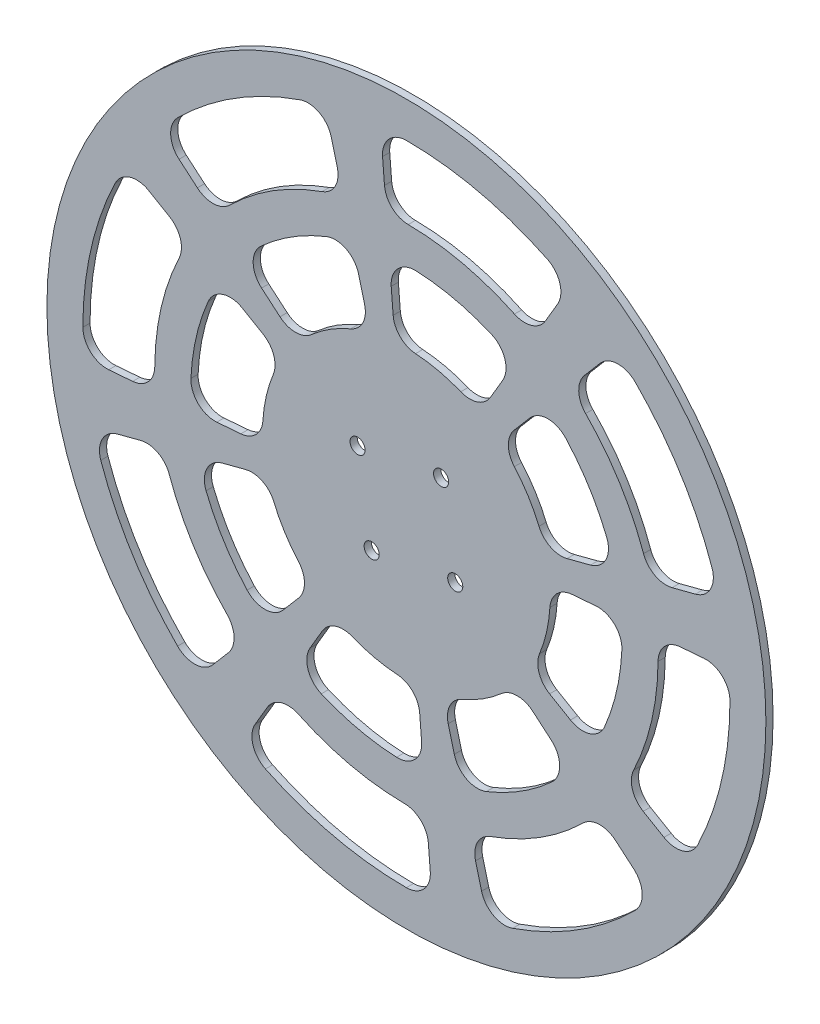
from build123d import *

# Parameters (mm, degrees)
SKETCH1_R           = 150
SKETCH1_R_2         = 3.15
BOSS_EXTRUDE2_DEPTH = 3
CUTOUTS_DEPTH       = 4


with BuildPart() as part:
    # Sketch1 → Boss-Extrude2 (new body)
    with BuildSketch(Plane.XY):
        Circle(SKETCH1_R)
        with Locations((20.373277645, -14.488946062)):
            Circle(SKETCH1_R_2, mode=Mode.SUBTRACT)
        with Locations((-14.488946062, -20.373277645)):
            Circle(SKETCH1_R_2, mode=Mode.SUBTRACT)
        with Locations((-20.373277645, 14.488946062)):
            Circle(SKETCH1_R_2, mode=Mode.SUBTRACT)
        with Locations((14.488946062, 20.373277645)):
            Circle(SKETCH1_R_2, mode=Mode.SUBTRACT)
    extrude(amount=BOSS_EXTRUDE2_DEPTH)

    # Weight Reduction Cutouts → Cutouts (cut, through all)
    with BuildSketch(Plane.XY):
        with BuildLine():
            Line((-94.859765477, 80.787529321), (-87.219963023, 74.281074644))
            ThreePointArc((-87.219963023, 74.281074644), (-80.372135282, 71.900885769), (-73.715641938, 74.773017417))
            ThreePointArc((-73.715641938, 74.773017417), (-55.766653389, 88.966737435), (-35.169050383, 98.935018548))
            ThreePointArc((-35.169050383, 98.935018548), (-29.682884625, 103.674219865), (-28.840536931, 110.874809716))
            Line((-28.840536931, 110.874809716), (-31.366747642, 120.586596031))
            ThreePointArc((-31.366747642, 120.586596031), (-36.330701425, 126.888386505), (-44.328270021, 127.514722589))
            ThreePointArc((-44.328270021, 127.514722589), (-71.699982928, 114.385805274), (-95.446060257, 95.472768795))
            ThreePointArc((-95.446060257, 95.472768795), (-98.36802157, 88.001788778), (-94.859765477, 80.787529321))
        make_face()
        with BuildLine():
            Line((-60.427762956, 51.46343813), (-52.745675776, 44.920971572))
            ThreePointArc((-52.745675776, 44.920971572), (-46.179173953, 42.534496218), (-39.653050302, 45.029274942))
            ThreePointArc((-39.653050302, 45.029274942), (-31.866659079, 50.838135677), (-23.244912146, 55.314320563))
            ThreePointArc((-23.244912146, 55.314320563), (-18.155193347, 60.100652493), (-17.441117348, 67.050782439))
            Line((-17.441117348, 67.050782439), (-19.981310113, 76.816321483))
            ThreePointArc((-19.981310113, 76.816321483), (-25.145953148, 83.222482327), (-33.366664052, 83.586277163))
            ThreePointArc((-33.366664052, 83.586277163), (-47.799988619, 76.257203516), (-60.686976599, 66.461198239))
            ThreePointArc((-60.686976599, 66.461198239), (-63.942485938, 58.903811562), (-60.427762956, 51.46343813))
        make_face()
        with BuildLine():
            Line((63.087959813, 107.447239735), (58.006990576, 98.79366905))
            ThreePointArc((58.006990576, 98.79366905), (52.319774897, 94.297712904), (45.089348498, 94.825896526))
            ThreePointArc((45.089348498, 94.825896526), (23.476004565, 102.341962116), (0.747677371, 104.997337959))
            ThreePointArc((0.747677371, 104.997337959), (-5.990077976, 107.673285777), (-9.149175714, 114.198478903))
            Line((-9.149175714, 114.198478903), (-9.950573612, 124.201393248))
            ThreePointArc((-9.950573612, 124.201393248), (-7.330033503, 131.783356706), (0.018885789, 134.999998679))
            ThreePointArc((0.018885789, 134.999998679), (30.183434441, 131.58252272), (58.821704713, 121.511345374))
            ThreePointArc((58.821704713, 121.511345374), (64.033953208, 115.413323894), (63.087959813, 107.447239735))
        make_face()
        with BuildLine():
            Line((40.188421949, 68.446261704), (35.079330598, 59.744795294))
            ThreePointArc((35.079330598, 59.744795294), (29.659918602, 55.335239261), (22.67649616, 55.549766173))
            ThreePointArc((22.67649616, 55.549766173), (13.414859752, 58.481121209), (3.8015649, 59.879446426))
            ThreePointArc((3.8015649, 59.879446426), (-2.577176342, 62.730037762), (-5.532901403, 69.060748635))
            Line((-5.532901403, 69.060748635), (-6.338734874, 79.119027043))
            ThreePointArc((-6.338734874, 79.119027043), (-3.56288082, 86.865450006), (4.082991278, 89.907336643))
            ThreePointArc((4.082991278, 89.907336643), (20.122289627, 87.721681813), (35.51062898, 82.698217813))
            ThreePointArc((35.51062898, 82.698217813), (41.06630761, 76.628055591), (40.188421949, 68.446261704))
        make_face()
        with BuildLine():
            Line((120.586596031, 31.366747642), (110.874809716, 28.840536931))
            ThreePointArc((110.874809716, 28.840536931), (103.674219865, 29.682884625), (98.935018548, 35.169050383))
            ThreePointArc((98.935018548, 35.169050383), (88.966737435, 55.766653389), (74.773017417, 73.715641938))
            ThreePointArc((74.773017417, 73.715641938), (71.900885769, 80.372135282), (74.281074644, 87.219963023))
            Line((74.281074644, 87.219963023), (80.787529321, 94.859765477))
            ThreePointArc((80.787529321, 94.859765477), (88.001788778, 98.36802157), (95.472768795, 95.446060257))
            ThreePointArc((95.472768795, 95.446060257), (114.385805274, 71.699982928), (127.514722589, 44.328270021))
            ThreePointArc((127.514722589, 44.328270021), (126.888386505, 36.330701425), (120.586596031, 31.366747642))
        make_face()
        with BuildLine():
            Line((76.816321483, 19.981310113), (67.050782439, 17.441117348))
            ThreePointArc((67.050782439, 17.441117348), (60.100652493, 18.155193347), (55.314320563, 23.244912146))
            ThreePointArc((55.314320563, 23.244912146), (50.838135677, 31.866659079), (45.029274942, 39.653050302))
            ThreePointArc((45.029274942, 39.653050302), (42.534496218, 46.179173953), (44.920971572, 52.745675776))
            Line((44.920971572, 52.745675776), (51.46343813, 60.427762956))
            ThreePointArc((51.46343813, 60.427762956), (58.903811562, 63.942485938), (66.461198239, 60.686976599))
            ThreePointArc((66.461198239, 60.686976599), (76.257203516, 47.799988619), (83.586277163, 33.366664052))
            ThreePointArc((83.586277163, 33.366664052), (83.222482327, 25.145953148), (76.816321483, 19.981310113))
        make_face()
        with BuildLine():
            Line((107.447239735, -63.087959813), (98.79366905, -58.006990576))
            ThreePointArc((98.79366905, -58.006990576), (94.297712904, -52.319774897), (94.825896526, -45.089348498))
            ThreePointArc((94.825896526, -45.089348498), (102.341962116, -23.476004565), (104.997337959, -0.747677371))
            ThreePointArc((104.997337959, -0.747677371), (107.673285777, 5.990077976), (114.198478903, 9.149175714))
            Line((114.198478903, 9.149175714), (124.201393248, 9.950573612))
            ThreePointArc((124.201393248, 9.950573612), (131.783356706, 7.330033503), (134.999998679, -0.018885789))
            ThreePointArc((134.999998679, -0.018885789), (131.58252272, -30.183434441), (121.511345374, -58.821704713))
            ThreePointArc((121.511345374, -58.821704713), (115.413323894, -64.033953208), (107.447239735, -63.087959813))
        make_face()
        with BuildLine():
            Line((68.446261704, -40.188421949), (59.744795294, -35.079330598))
            ThreePointArc((59.744795294, -35.079330598), (55.335239261, -29.659918602), (55.549766173, -22.67649616))
            ThreePointArc((55.549766173, -22.67649616), (58.481121209, -13.414859752), (59.879446426, -3.8015649))
            ThreePointArc((59.879446426, -3.8015649), (62.730037762, 2.577176342), (69.060748635, 5.532901403))
            Line((69.060748635, 5.532901403), (79.119027043, 6.338734874))
            ThreePointArc((79.119027043, 6.338734874), (86.865450006, 3.56288082), (89.907336643, -4.082991278))
            ThreePointArc((89.907336643, -4.082991278), (87.721681813, -20.122289627), (82.698217813, -35.51062898))
            ThreePointArc((82.698217813, -35.51062898), (76.628055591, -41.06630761), (68.446261704, -40.188421949))
        make_face()
        with BuildLine():
            Line((31.366747642, -120.586596031), (28.840536931, -110.874809716))
            ThreePointArc((28.840536931, -110.874809716), (29.682884625, -103.674219865), (35.169050383, -98.935018548))
            ThreePointArc((35.169050383, -98.935018548), (55.766653389, -88.966737435), (73.715641938, -74.773017417))
            ThreePointArc((73.715641938, -74.773017417), (80.372135282, -71.900885769), (87.219963023, -74.281074644))
            Line((87.219963023, -74.281074644), (94.859765477, -80.787529321))
            ThreePointArc((94.859765477, -80.787529321), (98.36802157, -88.001788778), (95.446060257, -95.472768795))
            ThreePointArc((95.446060257, -95.472768795), (71.699982928, -114.385805274), (44.328270021, -127.514722589))
            ThreePointArc((44.328270021, -127.514722589), (36.330701425, -126.888386505), (31.366747642, -120.586596031))
        make_face()
        with BuildLine():
            Line((19.981310113, -76.816321483), (17.441117348, -67.050782439))
            ThreePointArc((17.441117348, -67.050782439), (18.155193347, -60.100652493), (23.244912146, -55.314320563))
            ThreePointArc((23.244912146, -55.314320563), (31.866659079, -50.838135677), (39.653050302, -45.029274942))
            ThreePointArc((39.653050302, -45.029274942), (46.179173953, -42.534496218), (52.745675776, -44.920971572))
            Line((52.745675776, -44.920971572), (60.427762956, -51.46343813))
            ThreePointArc((60.427762956, -51.46343813), (63.942485938, -58.903811562), (60.686976599, -66.461198239))
            ThreePointArc((60.686976599, -66.461198239), (47.799988619, -76.257203516), (33.366664052, -83.586277163))
            ThreePointArc((33.366664052, -83.586277163), (25.145953148, -83.222482327), (19.981310113, -76.816321483))
        make_face()
        with BuildLine():
            Line((-63.087959813, -107.447239735), (-58.006990576, -98.79366905))
            ThreePointArc((-58.006990576, -98.79366905), (-52.319774897, -94.297712904), (-45.089348498, -94.825896526))
            ThreePointArc((-45.089348498, -94.825896526), (-23.476004565, -102.341962116), (-0.747677371, -104.997337959))
            ThreePointArc((-0.747677371, -104.997337959), (5.990077976, -107.673285777), (9.149175714, -114.198478903))
            Line((9.149175714, -114.198478903), (9.950573612, -124.201393248))
            ThreePointArc((9.950573612, -124.201393248), (7.330033503, -131.783356706), (-0.018885789, -134.999998679))
            ThreePointArc((-0.018885789, -134.999998679), (-30.183434441, -131.58252272), (-58.821704713, -121.511345374))
            ThreePointArc((-58.821704713, -121.511345374), (-64.033953208, -115.413323894), (-63.087959813, -107.447239735))
        make_face()
        with BuildLine():
            Line((-40.188421949, -68.446261704), (-35.079330598, -59.744795294))
            ThreePointArc((-35.079330598, -59.744795294), (-29.659918602, -55.335239261), (-22.67649616, -55.549766173))
            ThreePointArc((-22.67649616, -55.549766173), (-13.414859752, -58.481121209), (-3.8015649, -59.879446426))
            ThreePointArc((-3.8015649, -59.879446426), (2.577176342, -62.730037762), (5.532901403, -69.060748635))
            Line((5.532901403, -69.060748635), (6.338734874, -79.119027043))
            ThreePointArc((6.338734874, -79.119027043), (3.56288082, -86.865450006), (-4.082991278, -89.907336643))
            ThreePointArc((-4.082991278, -89.907336643), (-20.122289627, -87.721681813), (-35.51062898, -82.698217813))
            ThreePointArc((-35.51062898, -82.698217813), (-41.06630761, -76.628055591), (-40.188421949, -68.446261704))
        make_face()
        with BuildLine():
            Line((-120.586596031, -31.366747642), (-110.874809716, -28.840536931))
            ThreePointArc((-110.874809716, -28.840536931), (-103.674219865, -29.682884625), (-98.935018548, -35.169050383))
            ThreePointArc((-98.935018548, -35.169050383), (-88.966737435, -55.766653389), (-74.773017417, -73.715641938))
            ThreePointArc((-74.773017417, -73.715641938), (-71.900885769, -80.372135282), (-74.281074644, -87.219963023))
            Line((-74.281074644, -87.219963023), (-80.787529321, -94.859765477))
            ThreePointArc((-80.787529321, -94.859765477), (-88.001788778, -98.36802157), (-95.472768795, -95.446060257))
            ThreePointArc((-95.472768795, -95.446060257), (-114.385805274, -71.699982928), (-127.514722589, -44.328270021))
            ThreePointArc((-127.514722589, -44.328270021), (-126.888386505, -36.330701425), (-120.586596031, -31.366747642))
        make_face()
        with BuildLine():
            Line((-76.816321483, -19.981310113), (-67.050782439, -17.441117348))
            ThreePointArc((-67.050782439, -17.441117348), (-60.100652493, -18.155193347), (-55.314320563, -23.244912146))
            ThreePointArc((-55.314320563, -23.244912146), (-50.838135677, -31.866659079), (-45.029274942, -39.653050302))
            ThreePointArc((-45.029274942, -39.653050302), (-42.534496218, -46.179173953), (-44.920971572, -52.745675776))
            Line((-44.920971572, -52.745675776), (-51.46343813, -60.427762956))
            ThreePointArc((-51.46343813, -60.427762956), (-58.903811562, -63.942485938), (-66.461198239, -60.686976599))
            ThreePointArc((-66.461198239, -60.686976599), (-76.257203516, -47.799988619), (-83.586277163, -33.366664052))
            ThreePointArc((-83.586277163, -33.366664052), (-83.222482327, -25.145953148), (-76.816321483, -19.981310113))
        make_face()
        with BuildLine():
            Line((-107.447239735, 63.087959813), (-98.79366905, 58.006990576))
            ThreePointArc((-98.79366905, 58.006990576), (-94.297712904, 52.319774897), (-94.825896526, 45.089348498))
            ThreePointArc((-94.825896526, 45.089348498), (-102.341962116, 23.476004565), (-104.997337959, 0.747677371))
            ThreePointArc((-104.997337959, 0.747677371), (-107.673285777, -5.990077976), (-114.198478903, -9.149175714))
            Line((-114.198478903, -9.149175714), (-124.201393248, -9.950573612))
            ThreePointArc((-124.201393248, -9.950573612), (-131.783356706, -7.330033503), (-134.999998679, 0.018885789))
            ThreePointArc((-134.999998679, 0.018885789), (-131.58252272, 30.183434441), (-121.511345374, 58.821704713))
            ThreePointArc((-121.511345374, 58.821704713), (-115.413323894, 64.033953208), (-107.447239735, 63.087959813))
        make_face()
        with BuildLine():
            Line((-68.446261704, 40.188421949), (-59.744795294, 35.079330598))
            ThreePointArc((-59.744795294, 35.079330598), (-55.335239261, 29.659918602), (-55.549766173, 22.67649616))
            ThreePointArc((-55.549766173, 22.67649616), (-58.481121209, 13.414859752), (-59.879446426, 3.8015649))
            ThreePointArc((-59.879446426, 3.8015649), (-62.730037762, -2.577176342), (-69.060748635, -5.532901403))
            Line((-69.060748635, -5.532901403), (-79.119027043, -6.338734874))
            ThreePointArc((-79.119027043, -6.338734874), (-86.865450006, -3.56288082), (-89.907336643, 4.082991278))
            ThreePointArc((-89.907336643, 4.082991278), (-87.721681813, 20.122289627), (-82.698217813, 35.51062898))
            ThreePointArc((-82.698217813, 35.51062898), (-76.628055591, 41.06630761), (-68.446261704, 40.188421949))
        make_face()
    extrude(amount=CUTOUTS_DEPTH, mode=Mode.SUBTRACT)


solid = part.part
